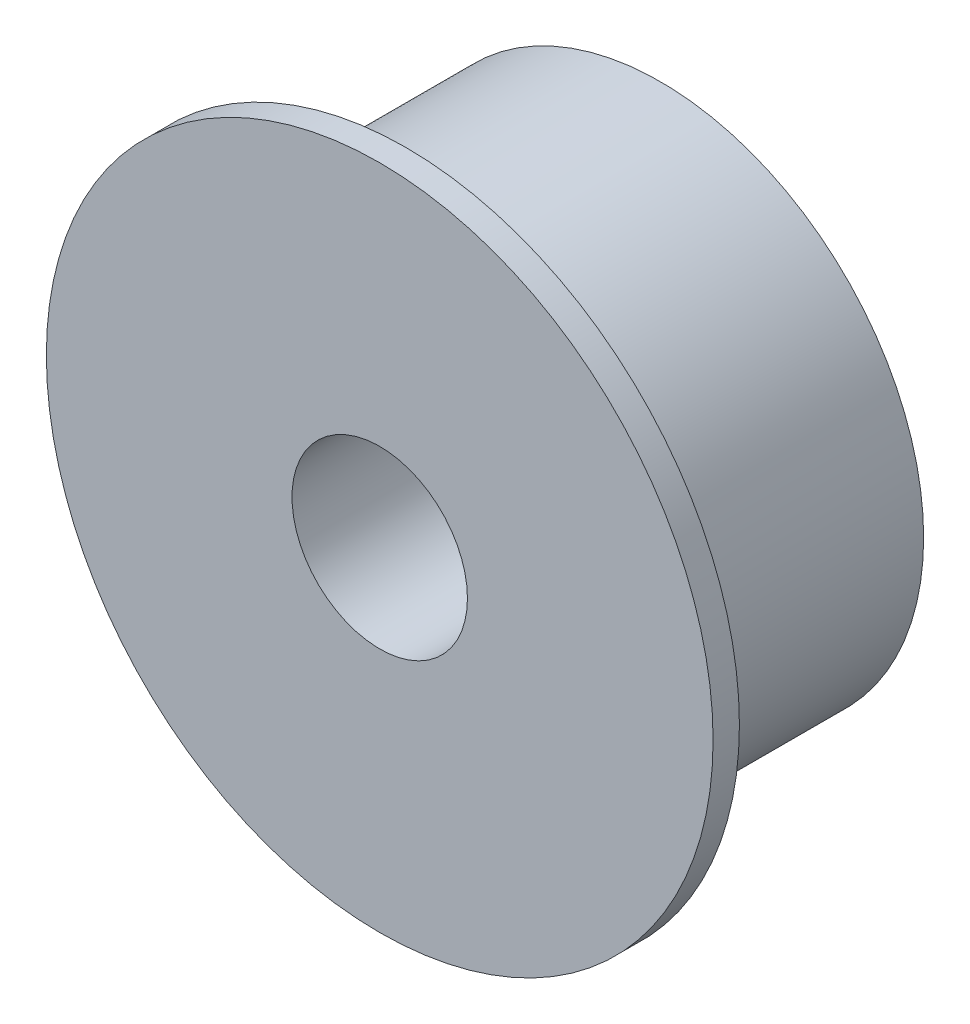
from build123d import *

# Parameters (mm, degrees)
SKETCH1_R           = 7.5
SKETCH1_R_2         = 2.5
BOSS_EXTRUDE1_DEPTH = 8
SKETCH2_R           = 9.5
SKETCH2_R_2         = 5
BOSS_EXTRUDE2_DEPTH = 0.75


with BuildPart() as part:
    # Sketch1 → Boss-Extrude1 (new body)
    with BuildSketch(Plane.XY):
        Circle(SKETCH1_R)
        Circle(SKETCH1_R_2, mode=Mode.SUBTRACT)
    extrude(amount=BOSS_EXTRUDE1_DEPTH)

    # Sketch2 → Boss-Extrude2 (add)
    with BuildSketch(Plane.XY.offset(8)):
        Circle(SKETCH2_R)
        Circle(SKETCH2_R_2, mode=Mode.SUBTRACT)
    extrude(amount=-BOSS_EXTRUDE2_DEPTH)


solid = part.part
